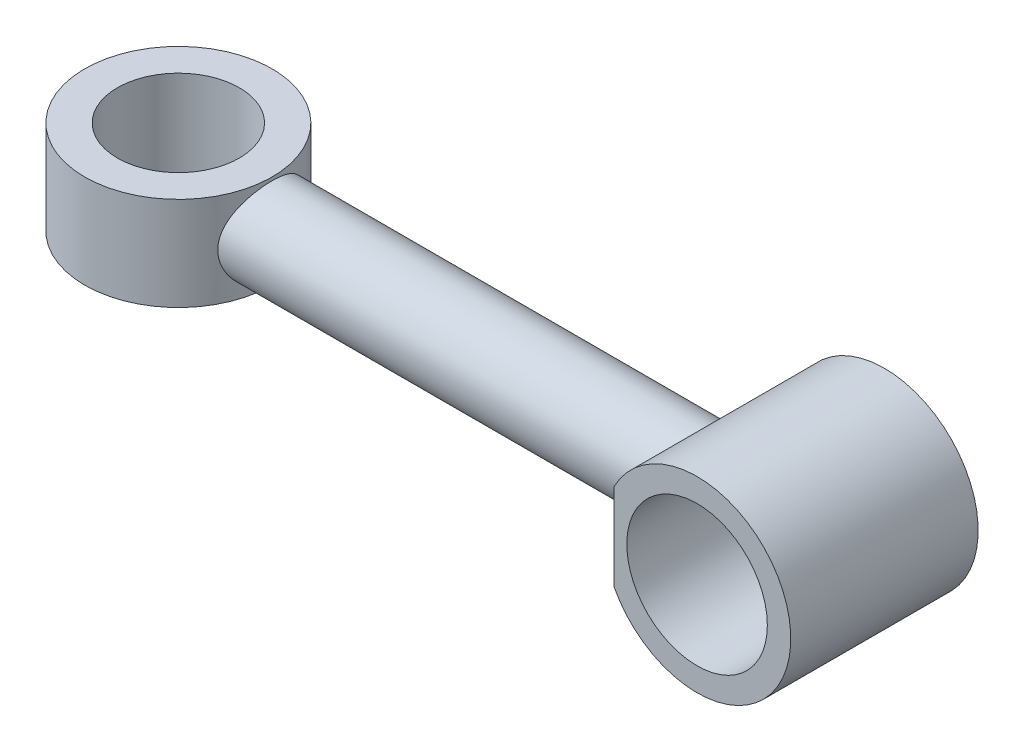
from build123d import *

# Parameters (mm, degrees)
SKETCH2_R                = 10
SKETCH2_R_2              = 7.5
BOSS_EXTRUDE1_DEPTH      = 20
CUT_EXTRUDE1_START       = -20
CUT_EXTRUDE1_DEPTH       = 20
SKETCH4_R                = 4.652081996
BOSS_EXTRUDE2_DEPTH      = 50
BOSS_EXTRUDE3_DEPTH      = 5
BOSS_EXTRUDE3_DEPTH_BACK = 5
SKETCH5_R                = 10
SKETCH5_R_2              = 6.506978502


with BuildPart() as part:
    # Sketch2 → Boss-Extrude1 (new body)
    with BuildSketch(Plane.XY):
        Circle(SKETCH2_R)
        Circle(SKETCH2_R_2, mode=Mode.SUBTRACT)
    extrude(amount=BOSS_EXTRUDE1_DEPTH)

    # Sketch3 → Cut-Extrude1 (cut)
    with BuildSketch(Plane.XY.offset(20).offset(CUT_EXTRUDE1_START)):
        with BuildLine():
            Line((-8.852012941, 4.652081996), (-8.852012941, -4.652081996))
            ThreePointArc((-8.852012941, -4.652081996), (-10, 0), (-8.852012941, 4.652081996))
        make_face()
    extrude(amount=CUT_EXTRUDE1_DEPTH, mode=Mode.SUBTRACT)

    # Sketch4 → Boss-Extrude2 (add)
    with BuildSketch(Plane.ZY.offset(8.852012941)):
        with Locations((10, 0)):
            Circle(SKETCH4_R)
    extrude(amount=BOSS_EXTRUDE2_DEPTH)

    # Sketch5 → Boss-Extrude3 (add, two sides: drawn at the far end of the back side and taken through both)
    with BuildSketch(Plane(origin=(0, 0, 0), x_dir=(1, 0, 0), z_dir=(0, 1, 0)).offset(-BOSS_EXTRUDE3_DEPTH_BACK)):
        with Locations((-65.358991443, -10)):
            Circle(SKETCH5_R)
        with Locations((-65.358991443, -10)):
            Circle(SKETCH5_R_2, mode=Mode.SUBTRACT)
    extrude(amount=BOSS_EXTRUDE3_DEPTH + BOSS_EXTRUDE3_DEPTH_BACK)


solid = part.part
